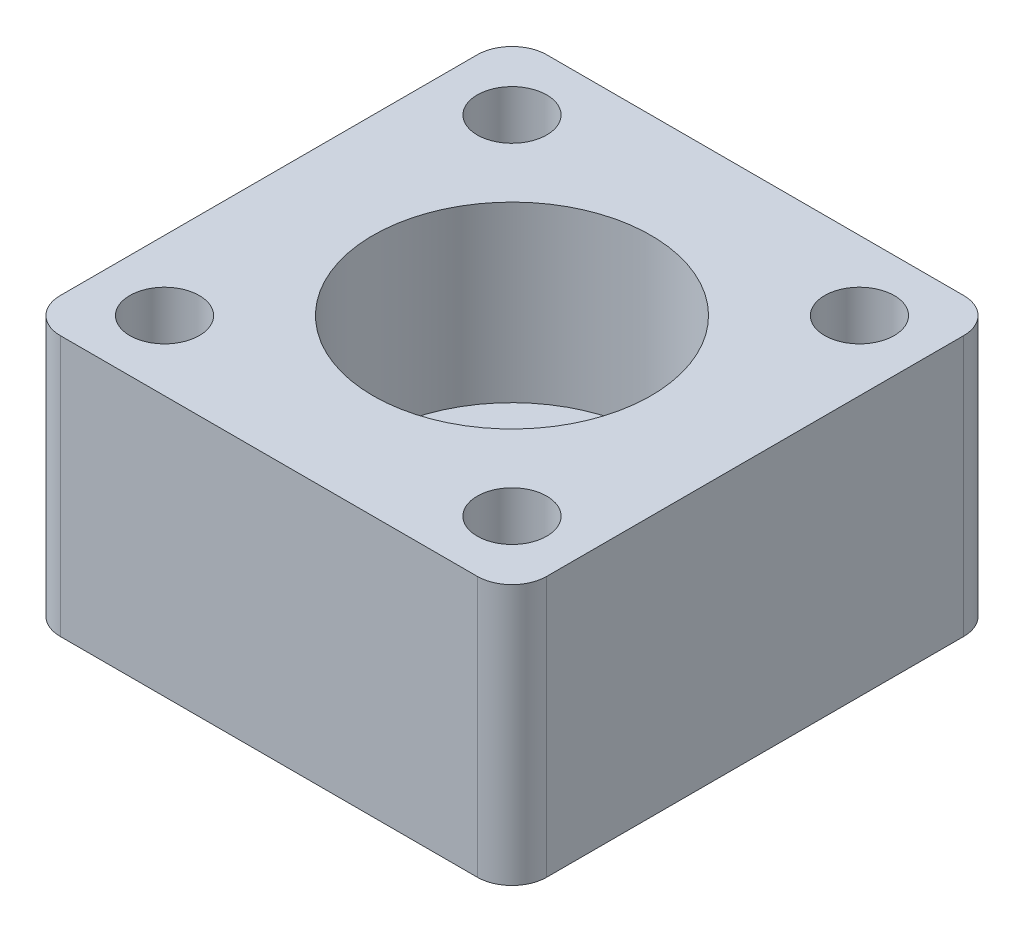
from build123d import *

# Parameters (mm, degrees)
SKETCH1_W           = 28
SKETCH1_H           = 28
BOSS_EXTRUDE1_DEPTH = 15
SKETCH2_R           = 5
SKETCH2_R_2         = 2
CUT_EXTRUDE1_DEPTH  = 16
SKETCH3_R           = 8
CUT_EXTRUDE2_DEPTH  = 10
FILLET1_R           = 2


with BuildPart() as part:
    # Sketch1 → Boss-Extrude1 (new body)
    with BuildSketch(Plane(origin=(0, 0, 0), x_dir=(1, 0, 0), z_dir=(0, 1, 0))):
        with Locations((14, 14)):
            Rectangle(SKETCH1_W, SKETCH1_H)
    extrude(amount=BOSS_EXTRUDE1_DEPTH)

    # Sketch2 → Cut-Extrude1 (cut, through all)
    with BuildSketch(Plane(origin=(0, 15, 0), x_dir=(-1, 0, 0), z_dir=(0, 1, 0))):
        with Locations((-14, -14)):
            Circle(SKETCH2_R)
        with Locations((-4, -24)):
            Circle(SKETCH2_R_2)
        with Locations((-24, -24)):
            Circle(SKETCH2_R_2)
        with Locations((-4, -4)):
            Circle(SKETCH2_R_2)
        with Locations((-24, -4)):
            Circle(SKETCH2_R_2)
    extrude(amount=-CUT_EXTRUDE1_DEPTH, mode=Mode.SUBTRACT)

    # Sketch3 → Cut-Extrude2 (cut)
    with BuildSketch(Plane(origin=(0, 15, 0), x_dir=(1, 0, 0), z_dir=(0, 1, 0))):
        with Locations((14, 14)):
            Circle(SKETCH3_R)
    extrude(amount=-CUT_EXTRUDE2_DEPTH, mode=Mode.SUBTRACT)

    # Fillet1
    fillet1_edges = [part.edges().sort_by_distance(p)[0] for p in [
        (0, 7.5, 0),
        (0, 7.5, -28),
        (28, 7.5, -28),
        (28, 7.5, 0),
    ]]
    fillet(fillet1_edges, radius=FILLET1_R)


solid = part.part
